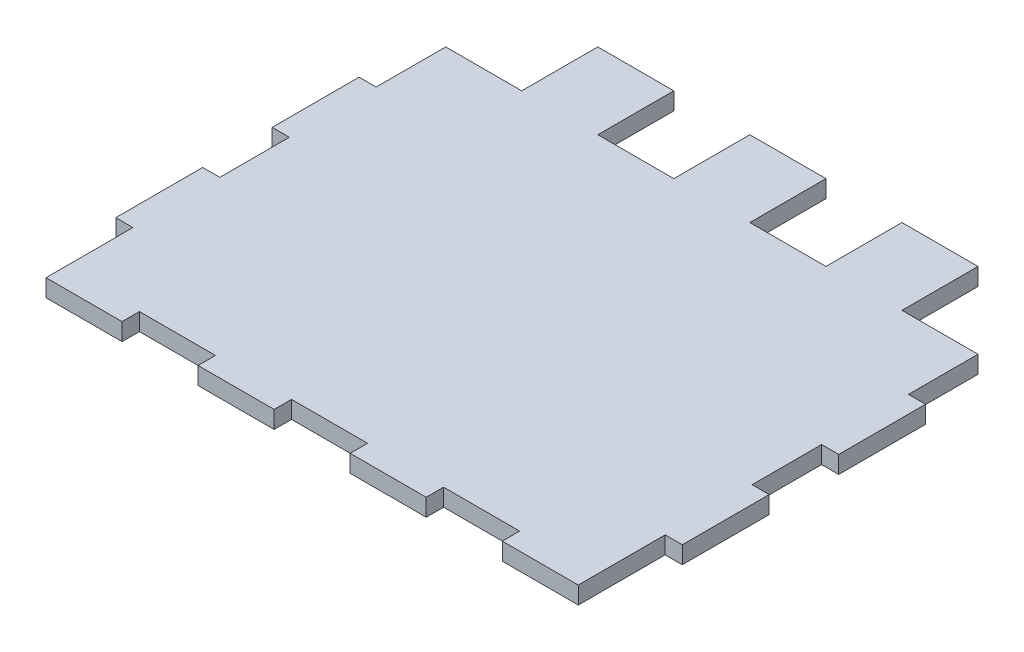
from build123d import *

# Parameters (mm, degrees)
BOSS_EXTRUDE2_DEPTH = 5.08


with BuildPart() as part:
    # Sketch3 → Boss-Extrude2 (new body)
    with BuildSketch(Plane(origin=(0, 0, 0), x_dir=(1, 0, 0), z_dir=(0, 1, 0))):
        Polygon((-283.144032451, 20.32), (-260.915461022, 20.32), (-260.915461022, 42.5485814), (-238.686889594, 42.5485814), (-238.686889594, 20.32), (-216.458318165, 20.32), (-216.458318165, 42.5485814), (-194.229746737, 42.5485814), (-194.229746737, 20.32), (-172.001175308, 20.32), (-172.001175308, 42.5485814), (-149.772603879, 42.5485814), (-149.772603879, 20.32), (-127.544032451, 20.32), (-127.544032451, 0), (-122.544032451, 0), (-122.544032451, -25.4), (-127.544032451, -25.4), (-127.544032451, -45.72), (-122.544032451, -45.72), (-122.544032451, -71.12), (-127.544032451, -71.12), (-127.544032451, -96.52), (-149.772603879, -96.52), (-149.772603879, -91.44), (-172.001175308, -91.44), (-172.001175308, -96.52), (-194.229746737, -96.52), (-194.229746737, -91.44), (-216.458318165, -91.44), (-216.458318165, -96.52), (-238.686889594, -96.52), (-238.686889594, -91.44), (-260.915461022, -91.44), (-260.915461022, -96.52), (-283.144032451, -96.52), (-283.144032451, -71.12), (-288.144032451, -71.12), (-288.144032451, -45.72), (-283.144032451, -45.72), (-283.144032451, -25.4), (-288.144032451, -25.4), (-288.144032451, 0), (-283.144032451, 0), align=None)
    extrude(amount=BOSS_EXTRUDE2_DEPTH)


solid = part.part
